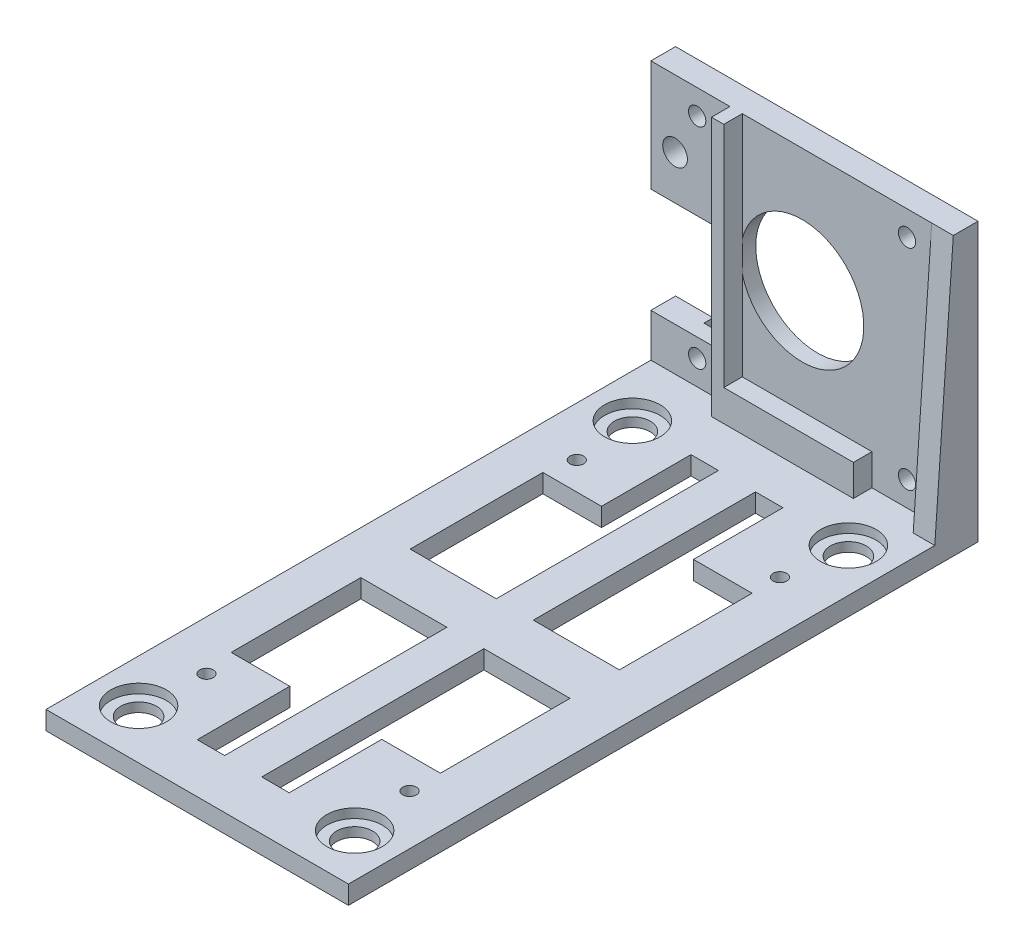
from build123d import *

# Parameters (mm, degrees)
SKETCH_1_R           = 2.9
SKETCH_1_R_2         = 1.1
EXTRUDE_1_DEPTH      = 3
SKETCH_2_R           = 4.5
CUT_EXTRUDE_1_DEPTH  = 1.5
SKETCH_3_W           = 49
SKETCH_3_H           = 4
EXTRUDE_2_DEPTH      = 42
EXTRUDE_2_DEPTH_BACK = 3
SKETCH_4_R           = 1.4
SKETCH_4_W           = 14.760499622
SKETCH_4_H           = 17
SKETCH_4_R_2         = 10
SKETCH_4_R_3         = 2
CUT_EXTRUDE_2_DEPTH  = 5
SKETCH_5_R           = 10
CUT_EXTRUDE_3_DEPTH  = 1.5
EXTRUDE_4_DEPTH      = 3.5
SKETCH_9_W           = 2
SKETCH_9_H           = 3
EXTRUDE_5_DEPTH      = 42
SKETCH_10_W          = 3
SKETCH_10_H          = 5.066593596
EXTRUDE_6_DEPTH      = 21


with BuildPart() as part:
    # 草图1 → 凸台-拉伸1 (new body)
    with BuildSketch(Plane(origin=(0, 0, 0), x_dir=(1, 0, 0), z_dir=(0, 1, 0))):
        Polygon((-42, 46), (-42, -1), (-42, -48), (0, -48), (7, -48), (7, 47), (7, 50), (-42, 50), align=None)
        with Locations((-35, -40)):
            Circle(SKETCH_1_R, mode=Mode.SUBTRACT)
        with Locations((-34, -30)):
            Circle(SKETCH_1_R_2, mode=Mode.SUBTRACT)
        Polygon((-35, -25), (-35, -4), (-21.05, -4), (-21.05, -40), (-25.5, -40), (-25.5, -25), align=None, mode=Mode.SUBTRACT)
        with Locations((0, -40)):
            Circle(SKETCH_1_R, mode=Mode.SUBTRACT)
        with Locations((-1.1, -30)):
            Circle(SKETCH_1_R_2, mode=Mode.SUBTRACT)
        Polygon((-1.1, -4), (-1.1, -25), (-10.6, -25), (-10.6, -40), (-15.05, -40), (-15.05, -4), align=None, mode=Mode.SUBTRACT)
        Polygon((-21.05, 4), (-35, 4), (-35, 25.5), (-25.5, 25.5), (-25.5, 40), (-21.05, 40), align=None, mode=Mode.SUBTRACT)
        with Locations((-34, 30)):
            Circle(SKETCH_1_R_2, mode=Mode.SUBTRACT)
        with Locations((-35, 40)):
            Circle(SKETCH_1_R, mode=Mode.SUBTRACT)
        Polygon((-10.6, 25.5), (-1.1, 25.5), (-1.1, 4), (-15.05, 4), (-15.05, 40), (-10.6, 40), align=None, mode=Mode.SUBTRACT)
        with Locations((-1.1, 30)):
            Circle(SKETCH_1_R_2, mode=Mode.SUBTRACT)
        with Locations((0, 40)):
            Circle(SKETCH_1_R, mode=Mode.SUBTRACT)
    extrude(amount=EXTRUDE_1_DEPTH)

    # 草图2 → 切除-拉伸1 (cut)
    with BuildSketch(Plane(origin=(0, 3, 0), x_dir=(1, 0, 0), z_dir=(0, 1, 0))):
        with Locations((-35, 40)):
            Circle(SKETCH_2_R)
        with Locations((0, 40)):
            Circle(SKETCH_2_R)
        with Locations((0, -40)):
            Circle(SKETCH_2_R)
        with Locations((-35, -40)):
            Circle(SKETCH_2_R)
    extrude(amount=-CUT_EXTRUDE_1_DEPTH, mode=Mode.SUBTRACT)

    # 草图3 → 凸台-拉伸2 (add, two sides)
    with BuildSketch(Plane(origin=(0, 3, 0), x_dir=(1, 0, 0), z_dir=(0, 1, 0))) as extrude_2_sk:
        with Locations((-17.5, 52)):
            Rectangle(SKETCH_3_W, SKETCH_3_H)
    extrude(amount=EXTRUDE_2_DEPTH)
    extrude(extrude_2_sk.sketch, amount=-EXTRUDE_2_DEPTH_BACK)

    # 草图4 → 切除-拉伸2 (cut, through all)
    with BuildSketch(Plane.XY.offset(-50)):
        with Locations((-34.5, 7)):
            Circle(SKETCH_4_R)
        with Locations((-36.880249811, 18.5)):
            Rectangle(SKETCH_4_W, SKETCH_4_H)
        with Locations((-34.5, 41)):
            Circle(SKETCH_4_R)
        with Locations((-0.5, 41)):
            Circle(SKETCH_4_R)
        with Locations((-0.5, 7)):
            Circle(SKETCH_4_R)
        with Locations((-17.5, 25)):
            Circle(SKETCH_4_R_2)
        with Locations((-38.080040601, 34.130797069)):
            Circle(SKETCH_4_R_3)
    extrude(amount=-CUT_EXTRUDE_2_DEPTH, mode=Mode.SUBTRACT)

    # 草图5 → 切除-拉伸3 (cut)
    with BuildSketch(Plane(origin=(0, 0, -54), x_dir=(-1, 0, 0), z_dir=(0, 0, -1))):
        with BuildLine():
            ThreePointArc((1.9, 41), (0.835827548, 39.640875334), (-0.738885511, 40.347954994))
            Line((-0.738885511, 40.347954994), (-0.738885511, 7.652045006))
            ThreePointArc((-0.738885511, 7.652045006), (0.835827548, 8.359124666), (1.9, 7))
            ThreePointArc((1.9, 7), (1.644381785, 6.193532189), (0.970870956, 5.681561324))
            Line((0.970870956, 5.681561324), (34.029129044, 5.681561324))
            ThreePointArc((34.029129044, 5.681561324), (33.693532189, 8.144381785), (35.9, 7))
            Line((35.9, 7), (35.9, 10))
            Line((35.9, 10), (29.5, 10))
            Line((29.5, 10), (29.5, 27))
            Line((29.5, 27), (35.9, 27))
            Line((35.9, 27), (35.9, 41))
            ThreePointArc((35.9, 41), (33.616753245, 39.913779411), (34.214464044, 42.370572588))
            Line((34.214464044, 42.370572588), (0.785535956, 42.370572588))
            ThreePointArc((0.785535956, 42.370572588), (1.586220589, 41.883246755), (1.9, 41))
        make_face()
        with Locations((17.5, 25)):
            Circle(SKETCH_5_R, mode=Mode.SUBTRACT)
    extrude(amount=-CUT_EXTRUDE_3_DEPTH, mode=Mode.SUBTRACT)

    # 草图7 → 凸台-拉伸4 (add)
    with BuildSketch(Plane(origin=(7, 0, 0), x_dir=(0, 0, -1), z_dir=(1, 0, 0))):
        Polygon((50, 3), (47, 3), (50, 45), align=None)
    extrude(amount=-EXTRUDE_4_DEPTH)

    # 草图9 → 凸台-拉伸5 (add)
    with BuildSketch(Plane(origin=(0, 3, 0), x_dir=(1, 0, 0), z_dir=(0, 1, 0))):
        with Locations((-28.188676473, 48.5)):
            Rectangle(SKETCH_9_W, SKETCH_9_H)
    extrude(amount=EXTRUDE_5_DEPTH)

    # 草图10 → 凸台-拉伸6 (add)
    with BuildSketch(Plane(origin=(-27.188676473, 0, 0), x_dir=(0, 0, -1), z_dir=(1, 0, 0))):
        with Locations((48.5, 5.533296798)):
            Rectangle(SKETCH_10_W, SKETCH_10_H)
    extrude(amount=EXTRUDE_6_DEPTH)


solid = part.part
